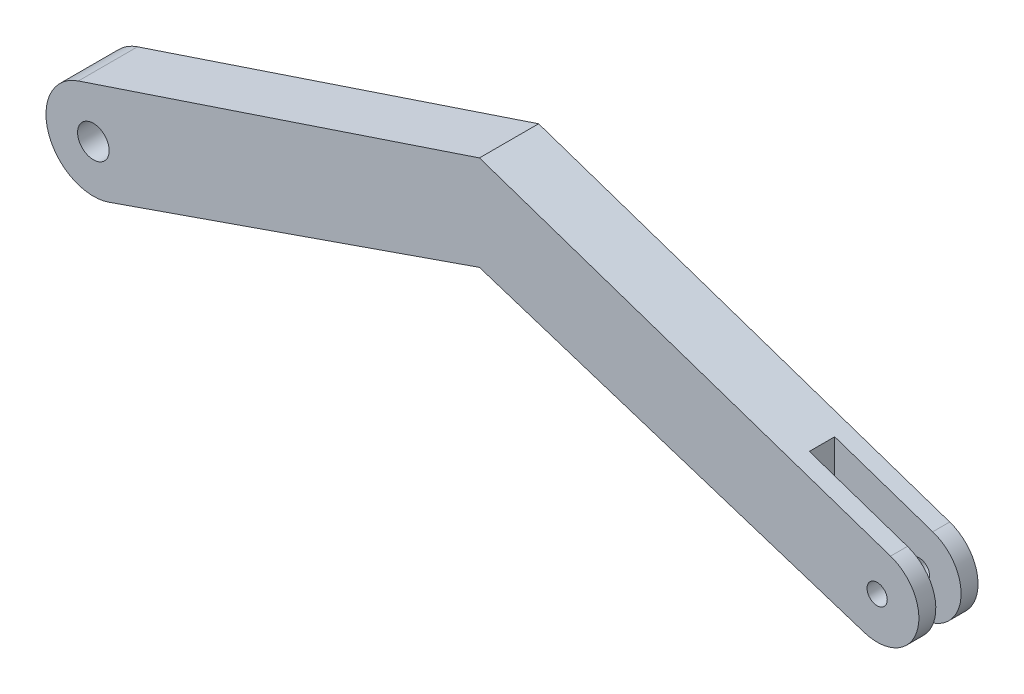
from build123d import *

# Parameters (mm, degrees)
SKETCH1_R               = 0.79375
BOSS_EXTRUDE1_DEPTH     = 2.9718
CUT_EXTRUDE1_DEPTH      = 43.810016021
CUT_EXTRUDE1_DEPTH_BACK = 43.810016021
SKETCH2_W               = 8.560637789
SKETCH2_H               = 1.27
CUT_EXTRUDE3_DEPTH      = 43.810016021
CUT_EXTRUDE3_DEPTH_BACK = 43.810016021
SKETCH1_4_R             = 0.508


with BuildPart() as part:
    # Sketch1 → Boss-Extrude1 (new body)
    with BuildSketch(Plane.XY):
        with BuildLine():
            ThreePointArc((-40.123930756, 2.258747435), (-41.624019757, -0.76794954), (-38.58806132, -2.249205074))
            Line((-38.58806132, -2.249205074), (-19.977544146, 4.220762208))
            Line((-19.977544146, 4.220762208), (-0.641288821, -1.994960876))
            ThreePointArc((-0.641288821, -1.994960876), (1.989850963, -0.656972903), (0.672616276, 1.984617745))
            Line((0.672616276, 1.984617745), (-19.977544146, 8.983262208))
            Line((-19.977544146, 8.983262208), (-40.123930756, 2.258747435))
        make_face()
        with Locations((-39.37, 0)):
            Circle(SKETCH1_R, mode=Mode.SUBTRACT)
    extrude(amount=BOSS_EXTRUDE1_DEPTH)

    # Sketch2 → Cut-Extrude1 (cut, two sides: drawn at the far end of the back side and taken through both)
    with BuildSketch(Plane(origin=(0, 0, 0), x_dir=(1, 0, 0), z_dir=(0, 1, 0)).offset(-CUT_EXTRUDE1_DEPTH_BACK)):
        with Locations((0.025818894, -1.4859)):
            Rectangle(SKETCH2_W, SKETCH2_H)
    extrude(amount=CUT_EXTRUDE1_DEPTH + CUT_EXTRUDE1_DEPTH_BACK, mode=Mode.SUBTRACT)

    # Sketch1_4 → Cut-Extrude3 (cut, two sides: drawn at the far end of the back side and taken through both)
    with BuildSketch(Plane.XY.offset(-CUT_EXTRUDE3_DEPTH_BACK)):
        Circle(SKETCH1_4_R)
    extrude(amount=CUT_EXTRUDE3_DEPTH + CUT_EXTRUDE3_DEPTH_BACK, mode=Mode.SUBTRACT)


solid = part.part
